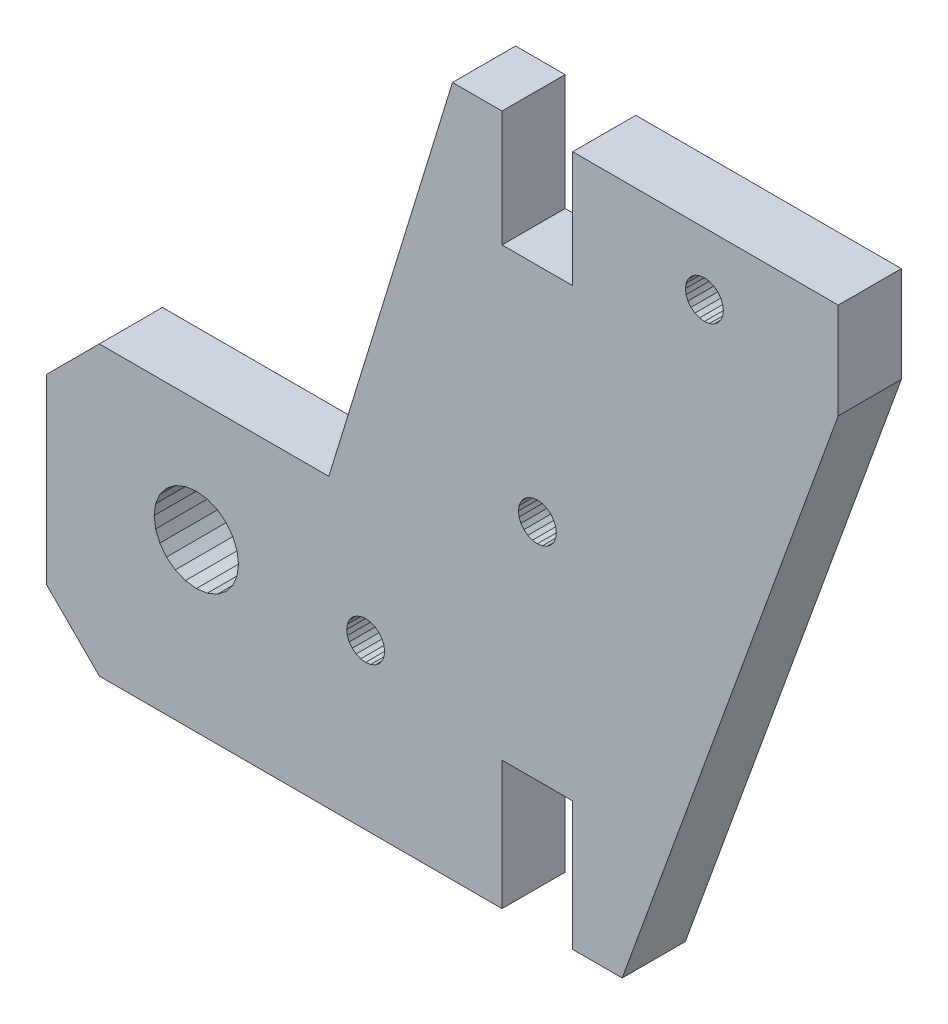
from build123d import *

# Parameters (mm, degrees)
BOSS_EXTRUDE1_DEPTH = 6


with BuildPart() as part:
    # Sketch1 → Boss-Extrude1 (new body)
    with BuildSketch(Plane.XY):
        Polygon((455.321482469, 30.265965349), (455.321482469, 18.043060934), (417.035477952, 18.043060934), (412.024250219, 23.054288667), (412.024250219, 40.388638702), (417.035477942, 45.399866425), (438.853709045, 45.399866425), (450.610703884, 83.714625961), (455.321482507, 83.714625961), (455.321482507, 72.692170576), (462.036078559, 72.692170576), (462.036078559, 83.721362841), (487.287246321, 83.721362841), (487.287246321, 74.600928376), (466.746857142, 18.043060933), (462.036078521, 18.043060933), (462.036078521, 30.265965349), align=None)
        Polygon((440.791723633, 34.541573026), (440.611499077, 34.106472458), (440.550027837, 33.639552034), (440.611499077, 33.172631611), (440.791723633, 32.737531042), (441.0784195, 32.363901714), (441.452048828, 32.077205847), (441.887149397, 31.89698129), (442.35406982, 31.83551005), (442.820990244, 31.89698129), (443.256090812, 32.077205847), (443.629720141, 32.363901714), (443.916416008, 32.737531042), (444.096640564, 33.172631611), (444.158111804, 33.639552034), (444.096640564, 34.106472458), (443.916416008, 34.541573026), (443.629720141, 34.915202354), (443.256090812, 35.201898222), (442.820990244, 35.382122778), (442.35406982, 35.443594018), (441.887149397, 35.382122778), (441.452048828, 35.201898222), (441.0784195, 34.915202354), align=None, mode=Mode.SUBTRACT)
        Polygon((422.383757586, 34.911643598), (422.247154831, 33.874042657), (422.383757586, 32.836441715), (422.7842566, 31.869551564), (423.421358527, 31.039264167), (424.251645924, 30.40216224), (425.218536076, 30.001663226), (426.256137017, 29.865060471), (427.293737958, 30.001663226), (428.26062811, 30.40216224), (429.090915506, 31.039264167), (429.728017433, 31.869551564), (430.128516448, 32.836441715), (430.265119203, 33.874042657), (430.128516448, 34.911643598), (429.728017433, 35.87853375), (429.090915506, 36.708821146), (428.26062811, 37.345923073), (427.293737958, 37.746422087), (426.256137017, 37.883024843), (425.218536076, 37.746422087), (424.251645924, 37.345923073), (423.421358527, 36.708821146), (422.7842566, 35.87853375), align=None, mode=Mode.SUBTRACT)
        Polygon((460.482822519, 51.565963652), (460.421351279, 52.032884076), (460.241126723, 52.467984644), (459.954430855, 52.841613972), (459.580801527, 53.128309839), (459.145700959, 53.308534396), (458.678780535, 53.370005636), (458.211860112, 53.308534396), (457.776759543, 53.128309839), (457.403130215, 52.841613972), (457.116434348, 52.467984644), (456.936209791, 52.032884076), (456.874738551, 51.565963652), (456.936209791, 51.099043228), (457.116434348, 50.66394266), (457.403130215, 50.290313332), (457.776759543, 50.003617465), (458.211860112, 49.823392908), (458.678780535, 49.761921668), (459.145700959, 49.823392908), (459.580801527, 50.003617465), (459.954430855, 50.290313332), (460.241126723, 50.66394266), (460.421351279, 51.099043228), align=None, mode=Mode.SUBTRACT)
        Polygon((476.121074094, 76.906092397), (475.834378227, 76.532463068), (475.460748898, 76.245767201), (475.02564833, 76.065542645), (474.558727906, 76.004071405), (474.091807483, 76.065542645), (473.656706914, 76.245767201), (473.283077586, 76.532463068), (472.996381719, 76.906092397), (472.816157162, 77.341192965), (472.754685923, 77.808113388), (472.816157162, 78.275033812), (472.996381719, 78.71013438), (473.283077586, 79.083763709), (473.656706914, 79.370459576), (474.091807483, 79.550684132), (474.558727906, 79.612155372), (475.02564833, 79.550684132), (475.460748898, 79.370459576), (475.834378227, 79.083763709), (476.121074094, 78.71013438), (476.30129865, 78.275033812), (476.36276989, 77.808113388), (476.30129865, 77.341192965), align=None, mode=Mode.SUBTRACT)
    extrude(amount=BOSS_EXTRUDE1_DEPTH)


solid = part.part
